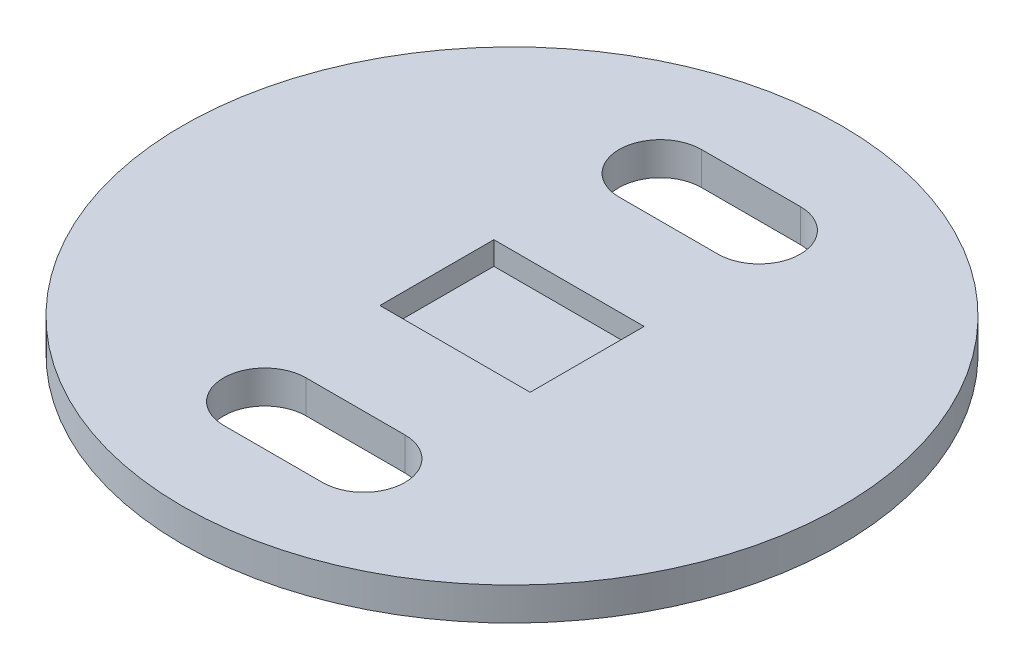
from build123d import *

# Parameters (mm, degrees)
SKETCH1_R           = 100
BOSS_EXTRUDE1_DEPTH = 10
CUT_EXTRUDE1_DEPTH  = 11
CUT_EXTRUDE2_DEPTH  = 7


with BuildPart() as part:
    # Sketch1 → Boss-Extrude1 (new body)
    with BuildSketch(Plane(origin=(0, 0, 0), x_dir=(1, 0, 0), z_dir=(0, 1, 0))):
        Circle(SKETCH1_R)
    extrude(amount=BOSS_EXTRUDE1_DEPTH)

    # Sketch2 → Cut-Extrude1 (cut, through all)
    with BuildSketch(Plane(origin=(0, 10, 0), x_dir=(1, 0, 0), z_dir=(0, 1, 0))):
        with BuildLine():
            Line((-15, -47.5), (15, -47.5))
            ThreePointArc((15, -47.5), (27.5, -60), (15, -72.5))
            Line((15, -72.5), (-15, -72.5))
            ThreePointArc((-15, -72.5), (-27.5, -60), (-15, -47.5))
        make_face()
    cut_extrude1 = extrude(amount=-CUT_EXTRUDE1_DEPTH, mode=Mode.SUBTRACT)

    # Mirror1: Cut-Extrude1 across plane
    add(cut_extrude1.mirror(Plane.XY), mode=Mode.SUBTRACT)

    # Sketch3 → Cut-Extrude2 (cut)
    with BuildSketch(Plane(origin=(0, 10, 0), x_dir=(1, 0, 0), z_dir=(0, 1, 0))):
        Polygon((-22.8, 17.3), (-22.8, -17.3), (0, 0), align=None)
        Polygon((-22.8, 17.3), (0, 0), (22.8, 17.3), align=None)
        Polygon((22.8, 17.3), (0, 0), (22.8, -17.3), align=None)
        Polygon((0, 0), (-22.8, -17.3), (22.8, -17.3), align=None)
    extrude(amount=-CUT_EXTRUDE2_DEPTH, mode=Mode.SUBTRACT)


solid = part.part
